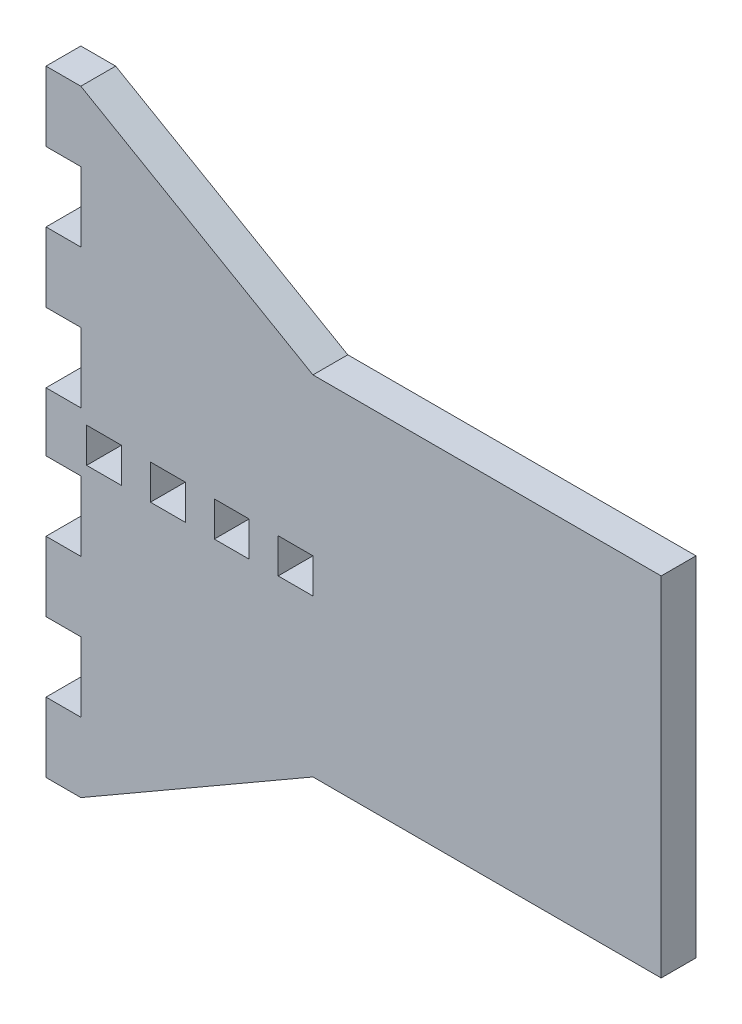
from build123d import *

# Parameters (mm, degrees)
BOSS_EXTRUDE1_DEPTH   = 3
SKETCH1_3_R           = 11
CUT_EXTRUDE1_DEPTH    = 1
SKETCH2_W             = 3
SKETCH2_H             = 6
BOSS_EXTRUDE2_DEPTH   = 3
BOSS_EXTRUDE2_2_DEPTH = 3
SKETCH2_H_2           = 5.08
BOSS_EXTRUDE2_3_DEPTH = 3
BOSS_EXTRUDE2_4_DEPTH = 3
BOSS_EXTRUDE2_5_DEPTH = 3
SKETCH3_W             = 3
SKETCH3_H             = 3
CUT_EXTRUDE2_DEPTH    = 3


with BuildPart() as part:
    # Sketch1 → Boss-Extrude1 (new body)
    with BuildSketch(Plane.XY):
        Polygon((-15, 15), (-35, 26.54), (-35, -26.54), (-15, -15), (15, -15), (15, 15), align=None)
    extrude(amount=BOSS_EXTRUDE1_DEPTH)

    # Sketch1_3 → Cut-Extrude1 (cut)
    with BuildSketch(Plane.XY):
        Circle(SKETCH1_3_R)
    extrude(amount=CUT_EXTRUDE1_DEPTH, mode=Mode.SUBTRACT)

    # Sketch3 → Cut-Extrude2 (cut)
    with BuildSketch(Plane(origin=(0, 0, 0), x_dir=(-1, 0, 0), z_dir=(0, 0, -1))):
        with Locations((22, 0)):
            Rectangle(SKETCH3_W, SKETCH3_H)
        with Locations((16.5, 0)):
            Rectangle(SKETCH3_W, SKETCH3_H)
        with Locations((27.5, 0)):
            Rectangle(SKETCH3_W, SKETCH3_H)
        with Locations((33, 0)):
            Rectangle(SKETCH3_W, SKETCH3_H)
    extrude(amount=-CUT_EXTRUDE2_DEPTH, mode=Mode.SUBTRACT)


with BuildPart() as body_2:
    # Sketch2 → Boss-Extrude2 (new body)
    with BuildSketch(Plane(origin=(0, 0, 0), x_dir=(-1, 0, 0), z_dir=(0, 0, -1))):
        with Locations((36.5, -23.54)):
            Rectangle(SKETCH2_W, SKETCH2_H)
    extrude(amount=-BOSS_EXTRUDE2_DEPTH)


with BuildPart() as body_3:
    # Sketch2 → Boss-Extrude2 2 (new body)
    with BuildSketch(Plane(origin=(0, 0, 0), x_dir=(-1, 0, 0), z_dir=(0, 0, -1))):
        with Locations((36.5, -11.54)):
            Rectangle(SKETCH2_W, SKETCH2_H)
    extrude(amount=-BOSS_EXTRUDE2_2_DEPTH)


with BuildPart() as body_4:
    # Sketch2 → Boss-Extrude2 3 (new body)
    with BuildSketch(Plane(origin=(0, 0, 0), x_dir=(-1, 0, 0), z_dir=(0, 0, -1))):
        with Locations((36.5, 0)):
            Rectangle(SKETCH2_W, SKETCH2_H_2)
    extrude(amount=-BOSS_EXTRUDE2_3_DEPTH)


with BuildPart() as body_5:
    # Sketch2 → Boss-Extrude2 4 (new body)
    with BuildSketch(Plane(origin=(0, 0, 0), x_dir=(-1, 0, 0), z_dir=(0, 0, -1))):
        with Locations((36.5, 11.54)):
            Rectangle(SKETCH2_W, SKETCH2_H)
    extrude(amount=-BOSS_EXTRUDE2_4_DEPTH)


with BuildPart() as body_6:
    # Sketch2 → Boss-Extrude2 5 (new body)
    with BuildSketch(Plane(origin=(0, 0, 0), x_dir=(-1, 0, 0), z_dir=(0, 0, -1))):
        with Locations((36.5, 23.54)):
            Rectangle(SKETCH2_W, SKETCH2_H)
    extrude(amount=-BOSS_EXTRUDE2_5_DEPTH)


with BuildPart() as body_4_1:
    add(body_4.part)

    # Combine1: union body 2, body 5, part, body 6, body 3
    add(body_2.part)
    add(body_5.part)
    add(part.part)
    add(body_6.part)
    add(body_3.part)


solid = body_4_1.part
